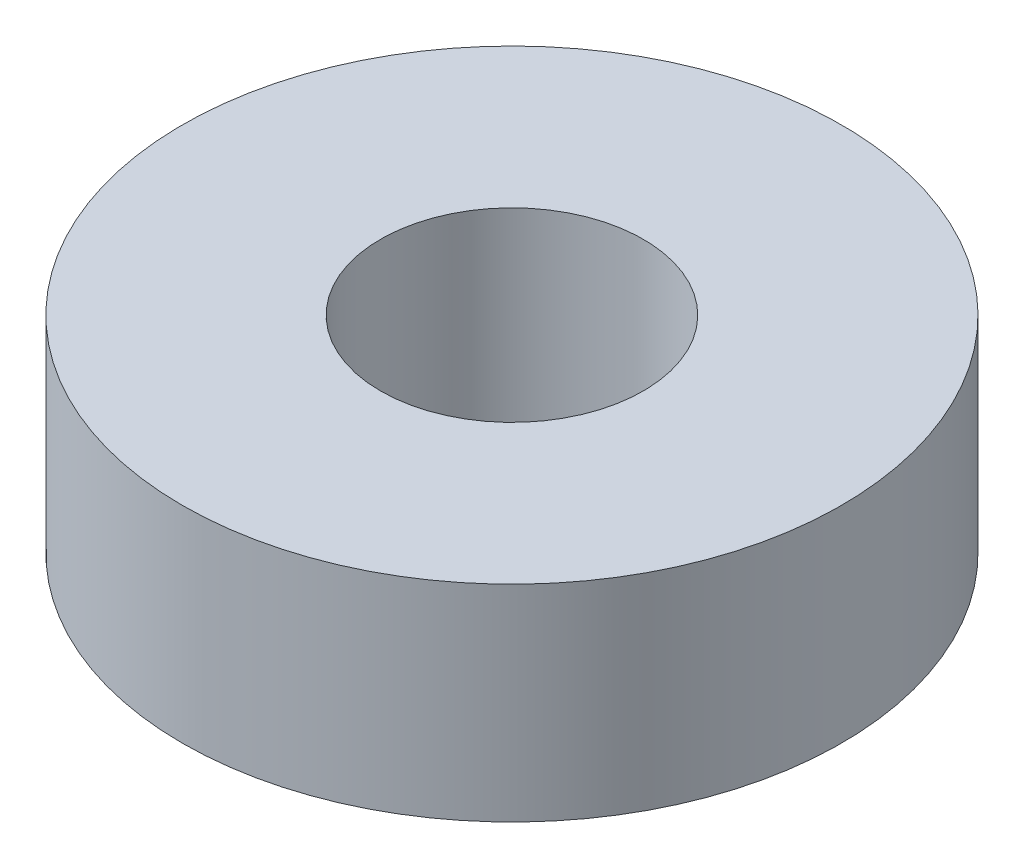
from build123d import *

# Parameters (mm, degrees)
SKETCH1_R           = 8
BOSS_EXTRUDE1_DEPTH = 5
SKETCH2_R           = 3.19
CUT_EXTRUDE1_DEPTH  = 5


with BuildPart() as part:
    # Sketch1 → Boss-Extrude1 (new body)
    with BuildSketch(Plane(origin=(0, 0, 0), x_dir=(1, 0, 0), z_dir=(0, 1, 0))):
        Circle(SKETCH1_R)
    extrude(amount=BOSS_EXTRUDE1_DEPTH)

    # Sketch2 → Cut-Extrude1 (cut)
    with BuildSketch(Plane(origin=(0, 0, 0), x_dir=(1, 0, 0), z_dir=(0, 1, 0))):
        Circle(SKETCH2_R)
    extrude(amount=CUT_EXTRUDE1_DEPTH, mode=Mode.SUBTRACT)


solid = part.part
